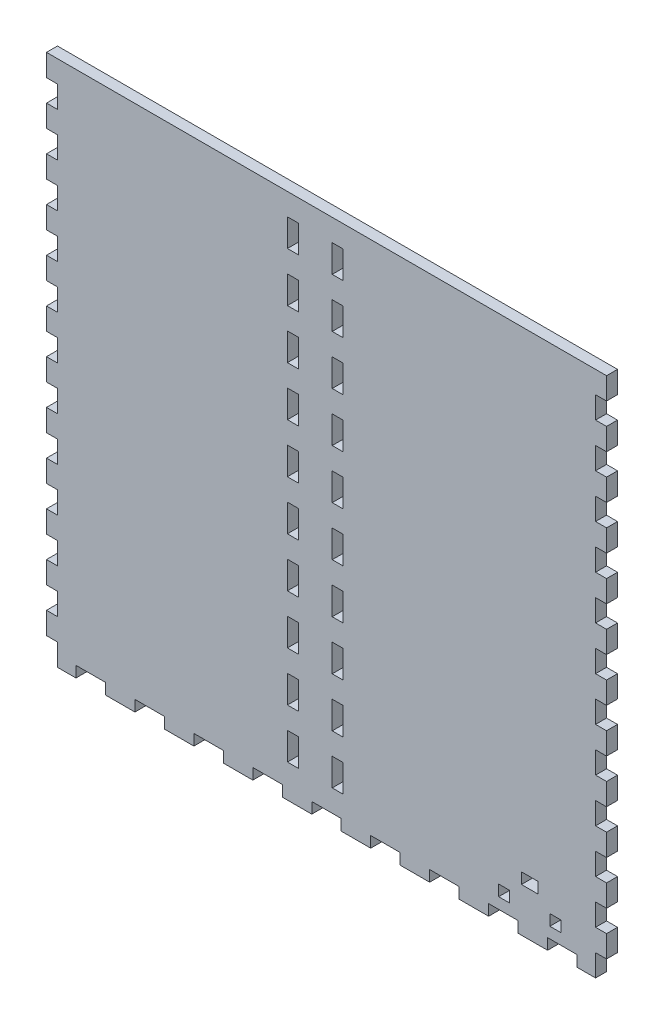
from build123d import *

# Parameters (mm, degrees)
SKETCH1_W              = 323.85
SKETCH1_H              = 139.7
BOSS_EXTRUDE1_DEPTH    = 6.35
SKETCH2_W              = 323.85
SKETCH2_H              = 139.7
SKETCH2_W_2            = 311.15
SKETCH2_H_2            = 127
BOSS_EXTRUDE2_DEPTH    = 298.45
SKETCH3_W              = 6.35
SKETCH3_H              = 16.933333333
SKETCH3_H_2            = 16.933333334
DOOR_SLOT_DEPTH        = 12.7
DOOR_GUIDE_HOLES_REACH = 372.007
SKETCH4_W              = 6.35
SKETCH4_H              = 15.875
LEVER_HOLES_W          = 9.652
LEVER_HOLES_H          = 6.35
LEVER_HOLES_W_2        = 6.35
CUT_EXTRUDE1_DEPTH     = 373.342363457
CUT_EXTRUDE2_REACH     = 452.179
SKETCH7_R              = 26.9875
CUT_EXTRUDE3_REACH     = 452.179
SKETCH8_R              = 3.175
SKETCH15_W             = 151.689001563
SKETCH15_H             = 328.434221774
CUT_EXTRUDE8_DEPTH     = 451.178725619
FRONT_BACK_W           = 6.35
FRONT_BACK_H           = 12.7
FRONT_BACK_W_2         = 17.044736842
FRONT_BACK_H_2         = 6.35
CUT_EXTRUDE9_DEPTH     = 373.342363457


with BuildPart() as part:
    # Sketch1 → Boss-Extrude1 (new body)
    with BuildSketch(Plane(origin=(0, 0, 0), x_dir=(1, 0, 0), z_dir=(0, 1, 0))):
        Rectangle(SKETCH1_W, SKETCH1_H)
    extrude(amount=BOSS_EXTRUDE1_DEPTH)

    # Sketch2 → Boss-Extrude2 (add)
    with BuildSketch(Plane(origin=(0, 6.35, 0), x_dir=(1, 0, 0), z_dir=(0, 1, 0))):
        Rectangle(SKETCH2_W, SKETCH2_H)
        Rectangle(SKETCH2_W_2, SKETCH2_H_2, mode=Mode.SUBTRACT)
    extrude(amount=BOSS_EXTRUDE2_DEPTH)

    # Sketch3 → Door Slot (cut)
    with BuildSketch(Plane.XY.offset(69.85)):
        with BuildLine():
            Line((-3.302, 283.21), (-3.302, 6.35))
            Line((-3.302, 6.35), (3.302, 6.35))
            Line((3.302, 6.35), (3.302, 292.354))
            Line((3.302, 292.354), (-16.256, 292.354))
            Line((-16.256, 292.354), (-16.256, 285.75))
            Line((-16.256, 285.75), (-5.842, 285.75))
            ThreePointArc((-5.842, 285.75), (-4.045948776, 285.006051224), (-3.302, 283.21))
        make_face()
        with Locations((12.827, 80.433333334)):
            Rectangle(SKETCH3_W, SKETCH3_H)
        with Locations((12.827, 50.8)):
            Rectangle(SKETCH3_W, SKETCH3_H_2)
        with Locations((12.827, 21.166666667)):
            Rectangle(SKETCH3_W, SKETCH3_H)
    extrude(amount=-DOOR_SLOT_DEPTH, mode=Mode.SUBTRACT)

    # Sketch4 → Door Guide Holes (cut, up to next)
    with BuildSketch(Plane.XY.offset(-63.5), mode=Mode.PRIVATE) as door_guide_holes_sk1:
        with Locations((-19.431, 284.1625)):
            Rectangle(SKETCH4_W, SKETCH4_H)
    door_guide_holes_tool1 = extrude(door_guide_holes_sk1.sketch, amount=-DOOR_GUIDE_HOLES_REACH, mode=Mode.PRIVATE) & part.part
    # Sketch4 → Door Guide Holes (cut, up to next)
    with BuildSketch(Plane.XY.offset(-63.5), mode=Mode.PRIVATE) as door_guide_holes_sk2:
        with Locations((-19.431, 255.5875)):
            Rectangle(SKETCH4_W, SKETCH4_H)
    door_guide_holes_tool2 = extrude(door_guide_holes_sk2.sketch, amount=-DOOR_GUIDE_HOLES_REACH, mode=Mode.PRIVATE) & part.part
    # Sketch4 → Door Guide Holes (cut, up to next)
    with BuildSketch(Plane.XY.offset(-63.5), mode=Mode.PRIVATE) as door_guide_holes_sk3:
        with Locations((-19.431, 227.0125)):
            Rectangle(SKETCH4_W, SKETCH4_H)
    door_guide_holes_tool3 = extrude(door_guide_holes_sk3.sketch, amount=-DOOR_GUIDE_HOLES_REACH, mode=Mode.PRIVATE) & part.part
    # Sketch4 → Door Guide Holes (cut, up to next)
    with BuildSketch(Plane.XY.offset(-63.5), mode=Mode.PRIVATE) as door_guide_holes_sk4:
        with Locations((-19.431, 198.4375)):
            Rectangle(SKETCH4_W, SKETCH4_H)
    door_guide_holes_tool4 = extrude(door_guide_holes_sk4.sketch, amount=-DOOR_GUIDE_HOLES_REACH, mode=Mode.PRIVATE) & part.part
    # Sketch4 → Door Guide Holes (cut, up to next)
    with BuildSketch(Plane.XY.offset(-63.5), mode=Mode.PRIVATE) as door_guide_holes_sk5:
        with Locations((-19.431, 169.8625)):
            Rectangle(SKETCH4_W, SKETCH4_H)
    door_guide_holes_tool5 = extrude(door_guide_holes_sk5.sketch, amount=-DOOR_GUIDE_HOLES_REACH, mode=Mode.PRIVATE) & part.part
    # Sketch4 → Door Guide Holes (cut, up to next)
    with BuildSketch(Plane.XY.offset(-63.5), mode=Mode.PRIVATE) as door_guide_holes_sk6:
        with Locations((-19.431, 141.2875)):
            Rectangle(SKETCH4_W, SKETCH4_H)
    door_guide_holes_tool6 = extrude(door_guide_holes_sk6.sketch, amount=-DOOR_GUIDE_HOLES_REACH, mode=Mode.PRIVATE) & part.part
    # Sketch4 → Door Guide Holes (cut, up to next)
    with BuildSketch(Plane.XY.offset(-63.5), mode=Mode.PRIVATE) as door_guide_holes_sk7:
        with Locations((-19.431, 112.7125)):
            Rectangle(SKETCH4_W, SKETCH4_H)
    door_guide_holes_tool7 = extrude(door_guide_holes_sk7.sketch, amount=-DOOR_GUIDE_HOLES_REACH, mode=Mode.PRIVATE) & part.part
    # Sketch4 → Door Guide Holes (cut, up to next)
    with BuildSketch(Plane.XY.offset(-63.5), mode=Mode.PRIVATE) as door_guide_holes_sk8:
        with Locations((-19.431, 84.1375)):
            Rectangle(SKETCH4_W, SKETCH4_H)
    door_guide_holes_tool8 = extrude(door_guide_holes_sk8.sketch, amount=-DOOR_GUIDE_HOLES_REACH, mode=Mode.PRIVATE) & part.part
    # Sketch4 → Door Guide Holes (cut, up to next)
    with BuildSketch(Plane.XY.offset(-63.5), mode=Mode.PRIVATE) as door_guide_holes_sk9:
        with Locations((-19.431, 55.5625)):
            Rectangle(SKETCH4_W, SKETCH4_H)
    door_guide_holes_tool9 = extrude(door_guide_holes_sk9.sketch, amount=-DOOR_GUIDE_HOLES_REACH, mode=Mode.PRIVATE) & part.part
    # Sketch4 → Door Guide Holes (cut, up to next)
    with BuildSketch(Plane.XY.offset(-63.5), mode=Mode.PRIVATE) as door_guide_holes_sk10:
        with Locations((-19.431, 26.9875)):
            Rectangle(SKETCH4_W, SKETCH4_H)
    door_guide_holes_tool10 = extrude(door_guide_holes_sk10.sketch, amount=-DOOR_GUIDE_HOLES_REACH, mode=Mode.PRIVATE) & part.part
    door_guide_holes_1 = door_guide_holes_tool1.solids().sort_by_distance((-19.431, 284.1625, -63.5))[0]
    add(door_guide_holes_1, mode=Mode.SUBTRACT)
    door_guide_holes_2 = door_guide_holes_tool2.solids().sort_by_distance((-19.431, 255.5875, -63.5))[0]
    add(door_guide_holes_2, mode=Mode.SUBTRACT)
    door_guide_holes_3 = door_guide_holes_tool3.solids().sort_by_distance((-19.431, 227.0125, -63.5))[0]
    add(door_guide_holes_3, mode=Mode.SUBTRACT)
    door_guide_holes_4 = door_guide_holes_tool4.solids().sort_by_distance((-19.431, 198.4375, -63.5))[0]
    add(door_guide_holes_4, mode=Mode.SUBTRACT)
    door_guide_holes_5 = door_guide_holes_tool5.solids().sort_by_distance((-19.431, 169.8625, -63.5))[0]
    add(door_guide_holes_5, mode=Mode.SUBTRACT)
    door_guide_holes_6 = door_guide_holes_tool6.solids().sort_by_distance((-19.431, 141.2875, -63.5))[0]
    add(door_guide_holes_6, mode=Mode.SUBTRACT)
    door_guide_holes_7 = door_guide_holes_tool7.solids().sort_by_distance((-19.431, 112.7125, -63.5))[0]
    add(door_guide_holes_7, mode=Mode.SUBTRACT)
    door_guide_holes_8 = door_guide_holes_tool8.solids().sort_by_distance((-19.431, 84.1375, -63.5))[0]
    add(door_guide_holes_8, mode=Mode.SUBTRACT)
    door_guide_holes_9 = door_guide_holes_tool9.solids().sort_by_distance((-19.431, 55.5625, -63.5))[0]
    add(door_guide_holes_9, mode=Mode.SUBTRACT)
    door_guide_holes_10 = door_guide_holes_tool10.solids().sort_by_distance((-19.431, 26.9875, -63.5))[0]
    add(door_guide_holes_10, mode=Mode.SUBTRACT)
    door_guide_holes = door_guide_holes_1 + door_guide_holes_2 + door_guide_holes_3 + door_guide_holes_4 + door_guide_holes_5 + door_guide_holes_6 + door_guide_holes_7 + door_guide_holes_8 + door_guide_holes_9 + door_guide_holes_10  # Door Guide Holes as one shape, for the pattern or mirror that repeats it

    # Mirror1: Door Guide Holes across plane
    add(door_guide_holes.mirror(Plane.ZY.offset(6.477)), mode=Mode.SUBTRACT)

    # Lever Holes → Cut-Extrude1 (cut, through all)
    with BuildSketch(Plane.XY.offset(69.85)):
        with Locations((117.5385, 28.575)):
            Rectangle(LEVER_HOLES_W, LEVER_HOLES_H)
        with Locations((102.743, 15.875)):
            Rectangle(LEVER_HOLES_W_2, LEVER_HOLES_H)
        with Locations((132.334, 15.875)):
            Rectangle(LEVER_HOLES_W_2, LEVER_HOLES_H)
    extrude(amount=-CUT_EXTRUDE1_DEPTH, mode=Mode.SUBTRACT)

    # Sketch7 → Cut-Extrude2 (cut, up to next)
    with BuildSketch(Plane(origin=(161.925, 0, 0), x_dir=(0, 0, -1), z_dir=(1, 0, 0)), mode=Mode.PRIVATE) as cut_extrude2_sk1:
        with Locations((0, 55.372)):
            Circle(SKETCH7_R)
    cut_extrude2_tool1 = extrude(cut_extrude2_sk1.sketch, amount=-CUT_EXTRUDE2_REACH, mode=Mode.PRIVATE) & part.part
    # Sketch7 → Cut-Extrude2 (cut, up to next)
    with BuildSketch(Plane(origin=(161.925, 0, 0), x_dir=(0, 0, -1), z_dir=(1, 0, 0)), mode=Mode.PRIVATE) as cut_extrude2_sk2:
        with BuildLine():
            Line((-37.211, 89.408), (-37.211, 92.583))
            Line((-37.211, 92.583), (-34.036, 92.583))
            ThreePointArc((-34.036, 92.583), (-39.45606403, 94.82806403), (-37.211, 89.408))
        make_face()
    cut_extrude2_tool2 = extrude(cut_extrude2_sk2.sketch, amount=-CUT_EXTRUDE2_REACH, mode=Mode.PRIVATE) & part.part
    # Sketch7 → Cut-Extrude2 (cut, up to next)
    with BuildSketch(Plane(origin=(161.925, 0, 0), x_dir=(0, 0, -1), z_dir=(1, 0, 0)), mode=Mode.PRIVATE) as cut_extrude2_sk3:
        with BuildLine():
            Line((-34.036, 92.583), (-37.211, 92.583))
            Line((-37.211, 92.583), (-37.211, 89.408))
            ThreePointArc((-37.211, 89.408), (-34.96593597, 90.33793597), (-34.036, 92.583))
        make_face()
    cut_extrude2_tool3 = extrude(cut_extrude2_sk3.sketch, amount=-CUT_EXTRUDE2_REACH, mode=Mode.PRIVATE) & part.part
    # Sketch7 → Cut-Extrude2 (cut, up to next)
    with BuildSketch(Plane(origin=(161.925, 0, 0), x_dir=(0, 0, -1), z_dir=(1, 0, 0)), mode=Mode.PRIVATE) as cut_extrude2_sk4:
        with BuildLine():
            Line((-37.211, 89.408), (-37.211, 92.583))
            Line((-37.211, 92.583), (-34.036, 92.583))
            ThreePointArc((-34.036, 92.583), (-39.45606403, 94.82806403), (-37.211, 89.408))
        make_face()
    cut_extrude2_tool4 = extrude(cut_extrude2_sk4.sketch, amount=-CUT_EXTRUDE2_REACH, mode=Mode.PRIVATE) & part.part
    # Sketch7 → Cut-Extrude2 (cut, up to next)
    with BuildSketch(Plane(origin=(161.925, 0, 0), x_dir=(0, 0, -1), z_dir=(1, 0, 0)), mode=Mode.PRIVATE) as cut_extrude2_sk5:
        with BuildLine():
            Line((-34.036, 92.583), (-37.211, 92.583))
            Line((-37.211, 92.583), (-37.211, 89.408))
            ThreePointArc((-37.211, 89.408), (-34.96593597, 90.33793597), (-34.036, 92.583))
        make_face()
    cut_extrude2_tool5 = extrude(cut_extrude2_sk5.sketch, amount=-CUT_EXTRUDE2_REACH, mode=Mode.PRIVATE) & part.part
    # Sketch7 → Cut-Extrude2 (cut, up to next)
    with BuildSketch(Plane(origin=(161.925, 0, 0), x_dir=(0, 0, -1), z_dir=(1, 0, 0)), mode=Mode.PRIVATE) as cut_extrude2_sk6:
        with BuildLine():
            ThreePointArc((40.386, 92.583), (37.211, 95.758), (34.036, 92.583))
            Line((34.036, 92.583), (37.211, 92.583))
            Line((37.211, 92.583), (37.211, 89.408))
            ThreePointArc((37.211, 89.408), (39.45606403, 90.33793597), (40.386, 92.583))
        make_face()
    cut_extrude2_tool6 = extrude(cut_extrude2_sk6.sketch, amount=-CUT_EXTRUDE2_REACH, mode=Mode.PRIVATE) & part.part
    # Sketch7 → Cut-Extrude2 (cut, up to next)
    with BuildSketch(Plane(origin=(161.925, 0, 0), x_dir=(0, 0, -1), z_dir=(1, 0, 0)), mode=Mode.PRIVATE) as cut_extrude2_sk7:
        with BuildLine():
            Line((37.211, 92.583), (34.036, 92.583))
            ThreePointArc((34.036, 92.583), (34.96593597, 90.33793597), (37.211, 89.408))
            Line((37.211, 89.408), (37.211, 92.583))
        make_face()
    cut_extrude2_tool7 = extrude(cut_extrude2_sk7.sketch, amount=-CUT_EXTRUDE2_REACH, mode=Mode.PRIVATE) & part.part
    # Sketch7 → Cut-Extrude2 (cut, up to next)
    with BuildSketch(Plane(origin=(161.925, 0, 0), x_dir=(0, 0, -1), z_dir=(1, 0, 0)), mode=Mode.PRIVATE) as cut_extrude2_sk8:
        with BuildLine():
            ThreePointArc((40.386, 92.583), (37.211, 95.758), (34.036, 92.583))
            Line((34.036, 92.583), (37.211, 92.583))
            Line((37.211, 92.583), (37.211, 89.408))
            ThreePointArc((37.211, 89.408), (39.45606403, 90.33793597), (40.386, 92.583))
        make_face()
    cut_extrude2_tool8 = extrude(cut_extrude2_sk8.sketch, amount=-CUT_EXTRUDE2_REACH, mode=Mode.PRIVATE) & part.part
    # Sketch7 → Cut-Extrude2 (cut, up to next)
    with BuildSketch(Plane(origin=(161.925, 0, 0), x_dir=(0, 0, -1), z_dir=(1, 0, 0)), mode=Mode.PRIVATE) as cut_extrude2_sk9:
        with BuildLine():
            Line((37.211, 92.583), (34.036, 92.583))
            ThreePointArc((34.036, 92.583), (34.96593597, 90.33793597), (37.211, 89.408))
            Line((37.211, 89.408), (37.211, 92.583))
        make_face()
    cut_extrude2_tool9 = extrude(cut_extrude2_sk9.sketch, amount=-CUT_EXTRUDE2_REACH, mode=Mode.PRIVATE) & part.part
    # Sketch7 → Cut-Extrude2 (cut, up to next)
    with BuildSketch(Plane(origin=(161.925, 0, 0), x_dir=(0, 0, -1), z_dir=(1, 0, 0)), mode=Mode.PRIVATE) as cut_extrude2_sk10:
        with BuildLine():
            ThreePointArc((-34.036, 18.161), (-34.96593597, 20.40606403), (-37.211, 21.336))
            Line((-37.211, 21.336), (-37.211, 18.161))
            Line((-37.211, 18.161), (-34.036, 18.161))
        make_face()
    cut_extrude2_tool10 = extrude(cut_extrude2_sk10.sketch, amount=-CUT_EXTRUDE2_REACH, mode=Mode.PRIVATE) & part.part
    # Sketch7 → Cut-Extrude2 (cut, up to next)
    with BuildSketch(Plane(origin=(161.925, 0, 0), x_dir=(0, 0, -1), z_dir=(1, 0, 0)), mode=Mode.PRIVATE) as cut_extrude2_sk11:
        with BuildLine():
            Line((-37.211, 18.161), (-37.211, 21.336))
            ThreePointArc((-37.211, 21.336), (-39.45606403, 15.91593597), (-34.036, 18.161))
            Line((-34.036, 18.161), (-37.211, 18.161))
        make_face()
    cut_extrude2_tool11 = extrude(cut_extrude2_sk11.sketch, amount=-CUT_EXTRUDE2_REACH, mode=Mode.PRIVATE) & part.part
    # Sketch7 → Cut-Extrude2 (cut, up to next)
    with BuildSketch(Plane(origin=(161.925, 0, 0), x_dir=(0, 0, -1), z_dir=(1, 0, 0)), mode=Mode.PRIVATE) as cut_extrude2_sk12:
        with BuildLine():
            ThreePointArc((-34.036, 18.161), (-34.96593597, 20.40606403), (-37.211, 21.336))
            Line((-37.211, 21.336), (-37.211, 18.161))
            Line((-37.211, 18.161), (-34.036, 18.161))
        make_face()
    cut_extrude2_tool12 = extrude(cut_extrude2_sk12.sketch, amount=-CUT_EXTRUDE2_REACH, mode=Mode.PRIVATE) & part.part
    # Sketch7 → Cut-Extrude2 (cut, up to next)
    with BuildSketch(Plane(origin=(161.925, 0, 0), x_dir=(0, 0, -1), z_dir=(1, 0, 0)), mode=Mode.PRIVATE) as cut_extrude2_sk13:
        with BuildLine():
            Line((-37.211, 18.161), (-37.211, 21.336))
            ThreePointArc((-37.211, 21.336), (-39.45606403, 15.91593597), (-34.036, 18.161))
            Line((-34.036, 18.161), (-37.211, 18.161))
        make_face()
    cut_extrude2_tool13 = extrude(cut_extrude2_sk13.sketch, amount=-CUT_EXTRUDE2_REACH, mode=Mode.PRIVATE) & part.part
    # Sketch7 → Cut-Extrude2 (cut, up to next)
    with BuildSketch(Plane(origin=(161.925, 0, 0), x_dir=(0, 0, -1), z_dir=(1, 0, 0)), mode=Mode.PRIVATE) as cut_extrude2_sk14:
        with BuildLine():
            ThreePointArc((40.386, 18.161), (39.45606403, 20.40606403), (37.211, 21.336))
            Line((37.211, 21.336), (37.211, 18.161))
            Line((37.211, 18.161), (34.036, 18.161))
            ThreePointArc((34.036, 18.161), (37.211, 14.986), (40.386, 18.161))
        make_face()
    cut_extrude2_tool14 = extrude(cut_extrude2_sk14.sketch, amount=-CUT_EXTRUDE2_REACH, mode=Mode.PRIVATE) & part.part
    # Sketch7 → Cut-Extrude2 (cut, up to next)
    with BuildSketch(Plane(origin=(161.925, 0, 0), x_dir=(0, 0, -1), z_dir=(1, 0, 0)), mode=Mode.PRIVATE) as cut_extrude2_sk15:
        with BuildLine():
            Line((37.211, 18.161), (37.211, 21.336))
            ThreePointArc((37.211, 21.336), (34.96593597, 20.40606403), (34.036, 18.161))
            Line((34.036, 18.161), (37.211, 18.161))
        make_face()
    cut_extrude2_tool15 = extrude(cut_extrude2_sk15.sketch, amount=-CUT_EXTRUDE2_REACH, mode=Mode.PRIVATE) & part.part
    # Sketch7 → Cut-Extrude2 (cut, up to next)
    with BuildSketch(Plane(origin=(161.925, 0, 0), x_dir=(0, 0, -1), z_dir=(1, 0, 0)), mode=Mode.PRIVATE) as cut_extrude2_sk16:
        with BuildLine():
            ThreePointArc((40.386, 18.161), (39.45606403, 20.40606403), (37.211, 21.336))
            Line((37.211, 21.336), (37.211, 18.161))
            Line((37.211, 18.161), (34.036, 18.161))
            ThreePointArc((34.036, 18.161), (37.211, 14.986), (40.386, 18.161))
        make_face()
    cut_extrude2_tool16 = extrude(cut_extrude2_sk16.sketch, amount=-CUT_EXTRUDE2_REACH, mode=Mode.PRIVATE) & part.part
    # Sketch7 → Cut-Extrude2 (cut, up to next)
    with BuildSketch(Plane(origin=(161.925, 0, 0), x_dir=(0, 0, -1), z_dir=(1, 0, 0)), mode=Mode.PRIVATE) as cut_extrude2_sk17:
        with BuildLine():
            Line((37.211, 18.161), (37.211, 21.336))
            ThreePointArc((37.211, 21.336), (34.96593597, 20.40606403), (34.036, 18.161))
            Line((34.036, 18.161), (37.211, 18.161))
        make_face()
    cut_extrude2_tool17 = extrude(cut_extrude2_sk17.sketch, amount=-CUT_EXTRUDE2_REACH, mode=Mode.PRIVATE) & part.part
    add(cut_extrude2_tool1.solids().sort_by_distance((161.925, 55.372, 0))[0], mode=Mode.SUBTRACT)
    add(cut_extrude2_tool2.solids().sort_by_distance((161.925, 93.032171, 37.660171))[0], mode=Mode.SUBTRACT)
    add(cut_extrude2_tool3.solids().sort_by_distance((161.925, 91.235488, 35.863488))[0], mode=Mode.SUBTRACT)
    add(cut_extrude2_tool4.solids().sort_by_distance((161.925, 93.032171, 37.660171))[0], mode=Mode.SUBTRACT)
    add(cut_extrude2_tool5.solids().sort_by_distance((161.925, 91.235488, 35.863488))[0], mode=Mode.SUBTRACT)
    add(cut_extrude2_tool6.solids().sort_by_distance((161.925, 93.032171, -37.660171))[0], mode=Mode.SUBTRACT)
    add(cut_extrude2_tool7.solids().sort_by_distance((161.925, 91.235488, -35.863488))[0], mode=Mode.SUBTRACT)
    add(cut_extrude2_tool8.solids().sort_by_distance((161.925, 93.032171, -37.660171))[0], mode=Mode.SUBTRACT)
    add(cut_extrude2_tool9.solids().sort_by_distance((161.925, 91.235488, -35.863488))[0], mode=Mode.SUBTRACT)
    add(cut_extrude2_tool10.solids().sort_by_distance((161.925, 19.508512, 35.863488))[0], mode=Mode.SUBTRACT)
    add(cut_extrude2_tool11.solids().sort_by_distance((161.925, 17.711829, 37.660171))[0], mode=Mode.SUBTRACT)
    add(cut_extrude2_tool12.solids().sort_by_distance((161.925, 19.508512, 35.863488))[0], mode=Mode.SUBTRACT)
    add(cut_extrude2_tool13.solids().sort_by_distance((161.925, 17.711829, 37.660171))[0], mode=Mode.SUBTRACT)
    add(cut_extrude2_tool14.solids().sort_by_distance((161.925, 17.711829, -37.660171))[0], mode=Mode.SUBTRACT)
    add(cut_extrude2_tool15.solids().sort_by_distance((161.925, 19.508512, -35.863488))[0], mode=Mode.SUBTRACT)
    add(cut_extrude2_tool16.solids().sort_by_distance((161.925, 17.711829, -37.660171))[0], mode=Mode.SUBTRACT)
    add(cut_extrude2_tool17.solids().sort_by_distance((161.925, 19.508512, -35.863488))[0], mode=Mode.SUBTRACT)

    # Sketch8 → Cut-Extrude3 (cut, up to next)
    with BuildSketch(Plane.ZY.offset(161.925), mode=Mode.PRIVATE) as cut_extrude3_sk1:
        with Locations((0, 19.05)):
            Circle(SKETCH8_R)
    cut_extrude3_tool1 = extrude(cut_extrude3_sk1.sketch, amount=-CUT_EXTRUDE3_REACH, mode=Mode.PRIVATE) & part.part
    add(cut_extrude3_tool1.solids().sort_by_distance((-161.925, 19.05, 0))[0], mode=Mode.SUBTRACT)

    # Sketch15 → Cut-Extrude8 (cut, through all)
    with BuildSketch(Plane.ZY.offset(161.925)):
        with Locations((12.344500781, 140.582889113)):
            Rectangle(SKETCH15_W, SKETCH15_H)
    extrude(amount=-CUT_EXTRUDE8_DEPTH, mode=Mode.SUBTRACT)

    # Front/Back → Cut-Extrude9 (cut, through all)
    with BuildSketch(Plane.XY.offset(69.85)):
        with Locations((-158.75, 6.35)):
            Rectangle(FRONT_BACK_W, FRONT_BACK_H)
        with Locations((-136.357894737, 3.175)):
            Rectangle(FRONT_BACK_W_2, FRONT_BACK_H_2)
        with Locations((-158.75, 31.75)):
            Rectangle(FRONT_BACK_W, FRONT_BACK_H)
        with Locations((-102.268421053, 3.175)):
            Rectangle(FRONT_BACK_W_2, FRONT_BACK_H_2)
        with Locations((-158.75, 57.15)):
            Rectangle(FRONT_BACK_W, FRONT_BACK_H)
        with Locations((-68.178947368, 3.175)):
            Rectangle(FRONT_BACK_W_2, FRONT_BACK_H_2)
        with Locations((-158.75, 82.55)):
            Rectangle(FRONT_BACK_W, FRONT_BACK_H)
        with Locations((-34.089473684, 3.175)):
            Rectangle(FRONT_BACK_W_2, FRONT_BACK_H_2)
        with Locations((-158.75, 107.95)):
            Rectangle(FRONT_BACK_W, FRONT_BACK_H)
        with Locations((0, 3.175)):
            Rectangle(FRONT_BACK_W_2, FRONT_BACK_H_2)
        with Locations((-158.75, 133.35)):
            Rectangle(FRONT_BACK_W, FRONT_BACK_H)
        with Locations((34.089473684, 3.175)):
            Rectangle(FRONT_BACK_W_2, FRONT_BACK_H_2)
        with Locations((-158.75, 158.75)):
            Rectangle(FRONT_BACK_W, FRONT_BACK_H)
        with Locations((68.178947368, 3.175)):
            Rectangle(FRONT_BACK_W_2, FRONT_BACK_H_2)
        with Locations((-158.75, 184.15)):
            Rectangle(FRONT_BACK_W, FRONT_BACK_H)
        with Locations((102.268421053, 3.175)):
            Rectangle(FRONT_BACK_W_2, FRONT_BACK_H_2)
        with Locations((-158.75, 209.55)):
            Rectangle(FRONT_BACK_W, FRONT_BACK_H)
        with Locations((136.357894737, 3.175)):
            Rectangle(FRONT_BACK_W_2, FRONT_BACK_H_2)
        with Locations((-158.75, 234.95)):
            Rectangle(FRONT_BACK_W, FRONT_BACK_H)
        with Locations((158.75, 6.35)):
            Rectangle(FRONT_BACK_W, FRONT_BACK_H)
        with Locations((-158.75, 260.35)):
            Rectangle(FRONT_BACK_W, FRONT_BACK_H)
        with Locations((158.75, 31.75)):
            Rectangle(FRONT_BACK_W, FRONT_BACK_H)
        with Locations((-158.75, 285.75)):
            Rectangle(FRONT_BACK_W, FRONT_BACK_H)
        with Locations((158.75, 57.15)):
            Rectangle(FRONT_BACK_W, FRONT_BACK_H)
        with Locations((158.75, 82.55)):
            Rectangle(FRONT_BACK_W, FRONT_BACK_H)
        with Locations((158.75, 107.95)):
            Rectangle(FRONT_BACK_W, FRONT_BACK_H)
        with Locations((158.75, 133.35)):
            Rectangle(FRONT_BACK_W, FRONT_BACK_H)
        with Locations((158.75, 158.75)):
            Rectangle(FRONT_BACK_W, FRONT_BACK_H)
        with Locations((158.75, 184.15)):
            Rectangle(FRONT_BACK_W, FRONT_BACK_H)
        with Locations((158.75, 209.55)):
            Rectangle(FRONT_BACK_W, FRONT_BACK_H)
        with Locations((158.75, 234.95)):
            Rectangle(FRONT_BACK_W, FRONT_BACK_H)
        with Locations((158.75, 260.35)):
            Rectangle(FRONT_BACK_W, FRONT_BACK_H)
        with Locations((158.75, 285.75)):
            Rectangle(FRONT_BACK_W, FRONT_BACK_H)
    extrude(amount=-CUT_EXTRUDE9_DEPTH, mode=Mode.SUBTRACT)


solid = part.part
